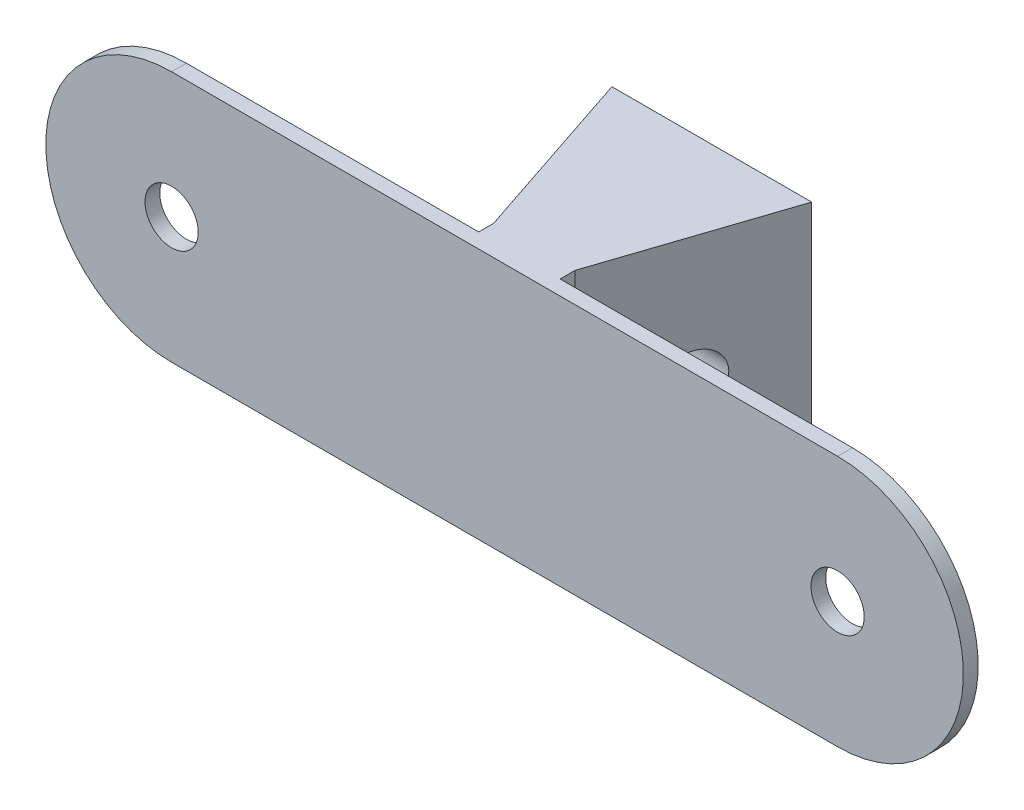
from build123d import *

# Parameters (mm, degrees)
BOSS_EXTRUDE1_DEPTH      = 1
M3_CLEARANCE_HOLE1_D     = 3.6
M3_CLEARANCE_HOLE1_DEPTH = 1
BOSS_EXTRUDE2_DEPTH      = 15.5
M3_CLEARANCE_HOLE2_D     = 3.6


with BuildPart() as part:
    # Sketch1 → Boss-Extrude1 (new body)
    with BuildSketch(Plane.XY):
        with BuildLine():
            Line((0, 8.5), (45, 8.5))
            ThreePointArc((45, 8.5), (53.5, 0), (45, -8.5))
            Line((45, -8.5), (0, -8.5))
            ThreePointArc((0, -8.5), (-8.5, 0), (0, 8.5))
        make_face()
    extrude(amount=BOSS_EXTRUDE1_DEPTH)

    # M3 Clearance Hole1
    with Locations(Plane.XY.offset(1)):
        with Locations((0, 0), (45, 0)):
            Hole(M3_CLEARANCE_HOLE1_D / 2, depth=M3_CLEARANCE_HOLE1_DEPTH)

    # Sketch4 → Boss-Extrude2 (add)
    with BuildSketch(Plane(origin=(0, 8.5, 0), x_dir=(1, 0, 0), z_dir=(0, 1, 0))):
        Polygon((19.75, 0), (19.75, 1), (15.75, 13), (29.25, 13), (25.25, 1), (25.25, 0), align=None)
    extrude(amount=-BOSS_EXTRUDE2_DEPTH)

    # M3 Clearance Hole2 (through all)
    with Locations(Plane(origin=(0, 0, 0), x_dir=(0, 0, -1), z_dir=(-1, 0, 0))):
        with Locations((7, 0)):
            Hole(M3_CLEARANCE_HOLE2_D / 2)


solid = part.part
